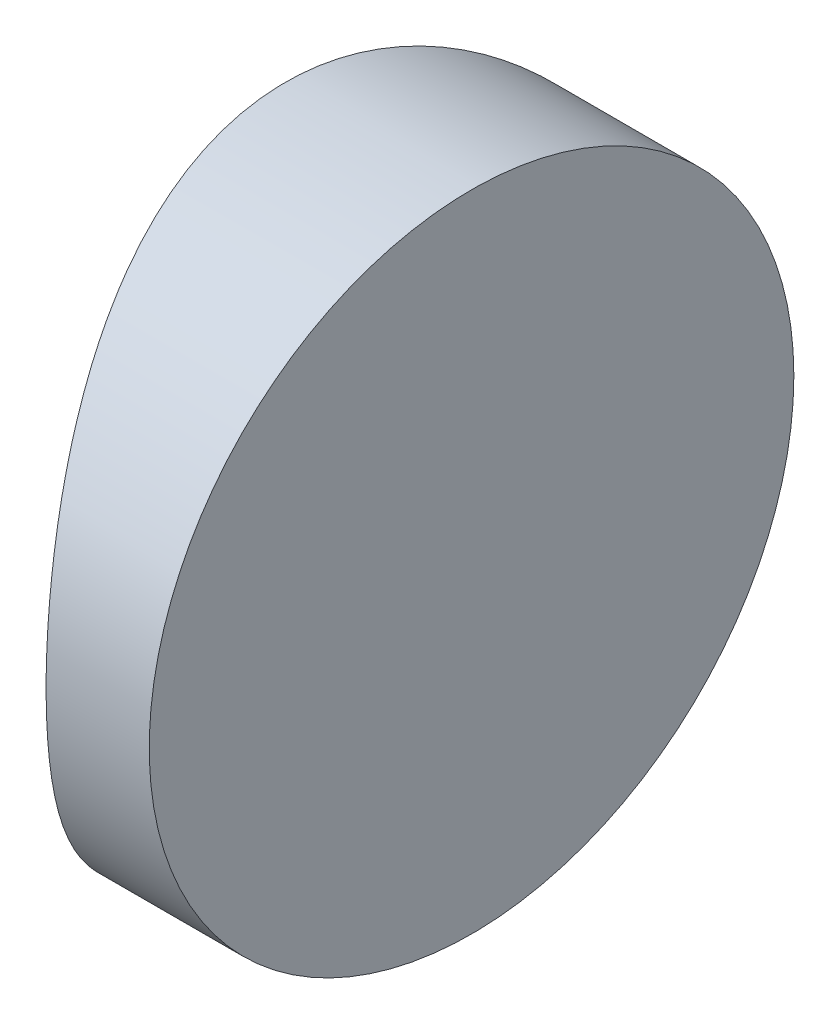
from build123d import *

# Parameters (mm, degrees)
EXTRUDE_1_DEPTH     = 12.5
CUT_EXTRUDE_8_DEPTH = 12.7


with BuildPart() as part:
    # 草图1 → 凸台-拉伸1 (new body)
    with BuildSketch(Plane(origin=(0, 0, 0), x_dir=(1, 0, 0), z_dir=(0, 1, 0))):
        with BuildLine():
            Line((-6.963912238, 6.25), (-4.964795665, 6.25))
            Line((-4.964795665, 6.25), (-4.964795665, -6.25))
            Line((-4.964795665, -6.25), (-6.963912238, -6.25))
            ThreePointArc((-6.963912238, -6.25), (-8.574795665, 0), (-6.963912238, 6.25))
        make_face()
    extrude(amount=EXTRUDE_1_DEPTH)

    # 草图2 → 切除-拉伸8 (cut)
    with BuildSketch(Plane(origin=(-4.964795665, 0, 0), x_dir=(0, 0, -1), z_dir=(1, 0, 0))):
        with BuildLine():
            Line((-6.25, 12.5), (-6.25, 6.25))
            ThreePointArc((-6.25, 6.25), (-4.419417382, 10.669417382), (0, 12.5))
            Line((0, 12.5), (-6.25, 12.5))
        make_face()
        with BuildLine():
            ThreePointArc((0, 12.5), (4.419417382, 10.669417382), (6.25, 6.25))
            Line((6.25, 6.25), (6.25, 12.5))
            Line((6.25, 12.5), (0, 12.5))
        make_face()
        with BuildLine():
            ThreePointArc((6.25, 6.25), (4.419417382, 1.830582618), (0, 0))
            Line((0, 0), (6.25, 0))
            Line((6.25, 0), (6.25, 6.25))
        make_face()
        with BuildLine():
            Line((-6.25, 6.25), (-6.25, 0))
            Line((-6.25, 0), (0, 0))
            ThreePointArc((0, 0), (-4.419417382, 1.830582618), (-6.25, 6.25))
        make_face()
    extrude(amount=-CUT_EXTRUDE_8_DEPTH, mode=Mode.SUBTRACT)


solid = part.part
